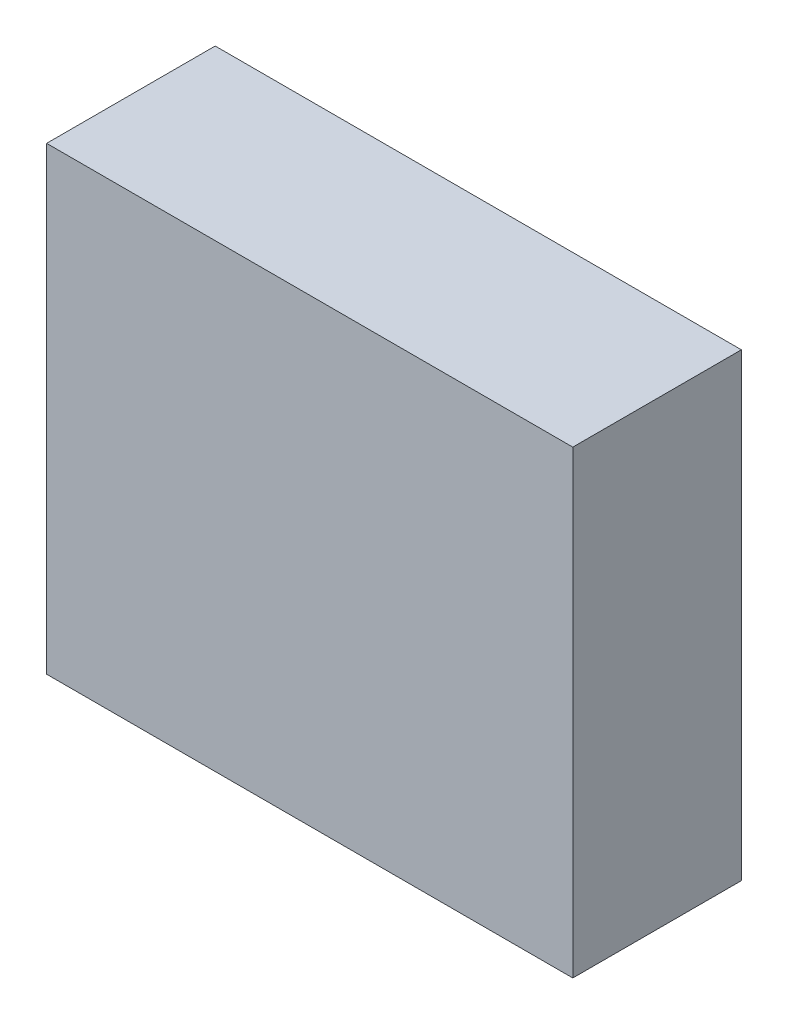
from build123d import *

# Parameters (mm, degrees)
SKETCH_1_W      = 10.3
SKETCH_1_H      = 9
EXTRUDE_1_DEPTH = 3.3


with BuildPart() as part:
    # Эскиз1 → Бобышка-Вытянуть1 (new body)
    with BuildSketch(Plane.XY):
        with Locations((-6.09982699, -13.847932114)):
            Rectangle(SKETCH_1_W, SKETCH_1_H)
    extrude(amount=EXTRUDE_1_DEPTH)


solid = part.part
